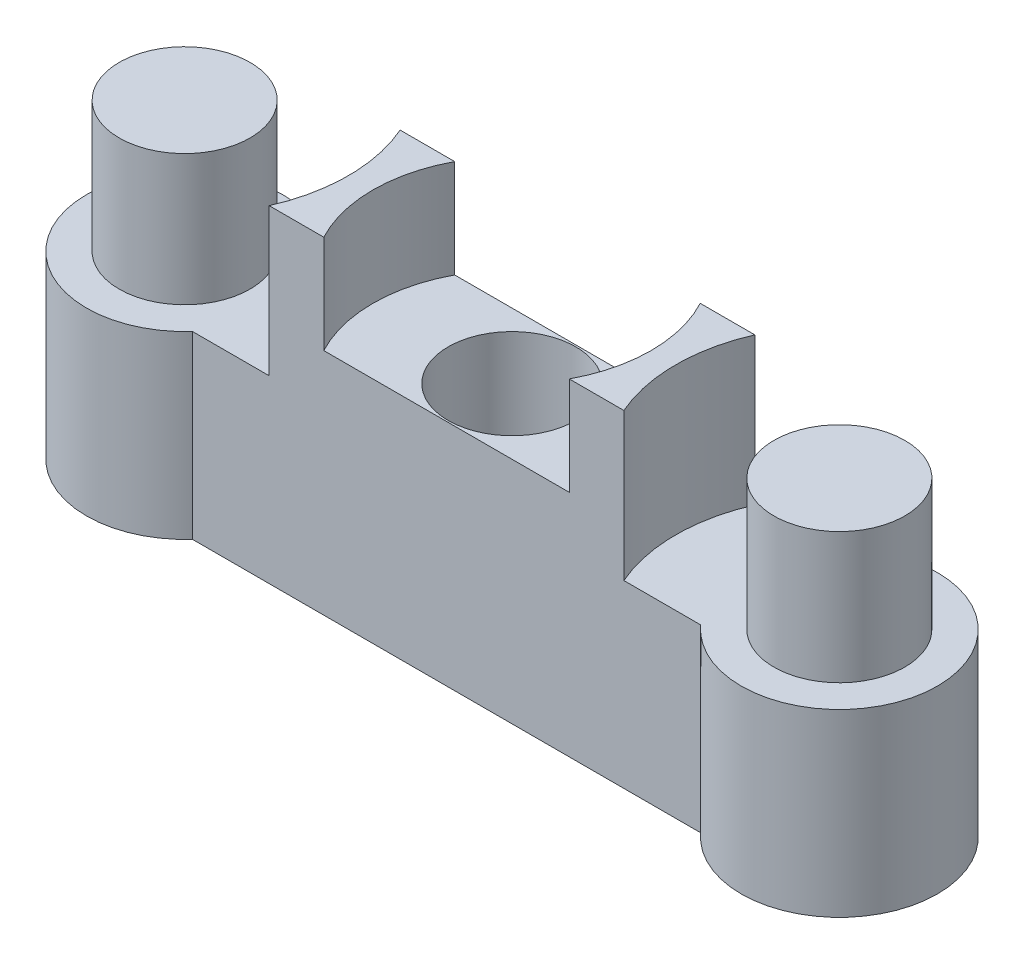
from build123d import *

# Parameters (mm, degrees)
EXTRUDE_1_DEPTH     = 10
SKETCH_2_R          = 5
CUT_EXTRUDE_1_DEPTH = 4.5
SKETCH_3_R          = 2
EXTRUDE_2_DEPTH     = 4
SKETCH_4_R          = 1
CUT_EXTRUDE_2_DEPTH = 11
SKETCH_5_R          = 1.95
CUT_EXTRUDE_3_DEPTH = 8
SKETCH_6_R          = 4.25
CUT_EXTRUDE_4_DEPTH = 3


with BuildPart() as part:
    # 草图1 → 凸台-拉伸1 (new body)
    with BuildSketch(Plane(origin=(0, 0, 0), x_dir=(1, 0, 0), z_dir=(0, 1, 0))):
        with BuildLine():
            Line((7.763932023, -2), (-7.763932023, -2))
            ThreePointArc((-7.763932023, -2), (-13, 0), (-7.763932023, 2))
            Line((-7.763932023, 2), (7.763932023, 2))
            ThreePointArc((7.763932023, 2), (13, 0), (7.763932023, -2))
        make_face()
    extrude(amount=EXTRUDE_1_DEPTH)

    # 草图2 → 切除-拉伸1 (cut)
    with BuildSketch(Plane(origin=(0, 10, 0), x_dir=(1, 0, 0), z_dir=(0, 1, 0))):
        with Locations((-10, 0)):
            Circle(SKETCH_2_R)
        with Locations((10, 0)):
            Circle(SKETCH_2_R)
    extrude(amount=-CUT_EXTRUDE_1_DEPTH, mode=Mode.SUBTRACT)

    # 草图3 → 凸台-拉伸2 (add)
    with BuildSketch(Plane(origin=(0, 5.5, 0), x_dir=(1, 0, 0), z_dir=(0, 1, 0))):
        with Locations((-10, 0)):
            Circle(SKETCH_3_R)
        with Locations((10, 0)):
            Circle(SKETCH_3_R)
    extrude(amount=EXTRUDE_2_DEPTH)

    # 草图4 → 切除-拉伸2 (cut, through all)
    with BuildSketch(Plane(origin=(0, 10, 0), x_dir=(1, 0, 0), z_dir=(0, 1, 0))):
        Circle(SKETCH_4_R)
    extrude(amount=-CUT_EXTRUDE_2_DEPTH, mode=Mode.SUBTRACT)

    # 草图5 → 切除-拉伸3 (cut)
    with BuildSketch(Plane(origin=(0, 10, 0), x_dir=(1, 0, 0), z_dir=(0, 1, 0))):
        Circle(SKETCH_5_R)
    extrude(amount=-CUT_EXTRUDE_3_DEPTH, mode=Mode.SUBTRACT)

    # 草图6 → 切除-拉伸4 (cut)
    with BuildSketch(Plane(origin=(0, 10, 0), x_dir=(1, 0, 0), z_dir=(0, 1, 0))):
        Circle(SKETCH_6_R)
    extrude(amount=-CUT_EXTRUDE_4_DEPTH, mode=Mode.SUBTRACT)


solid = part.part
